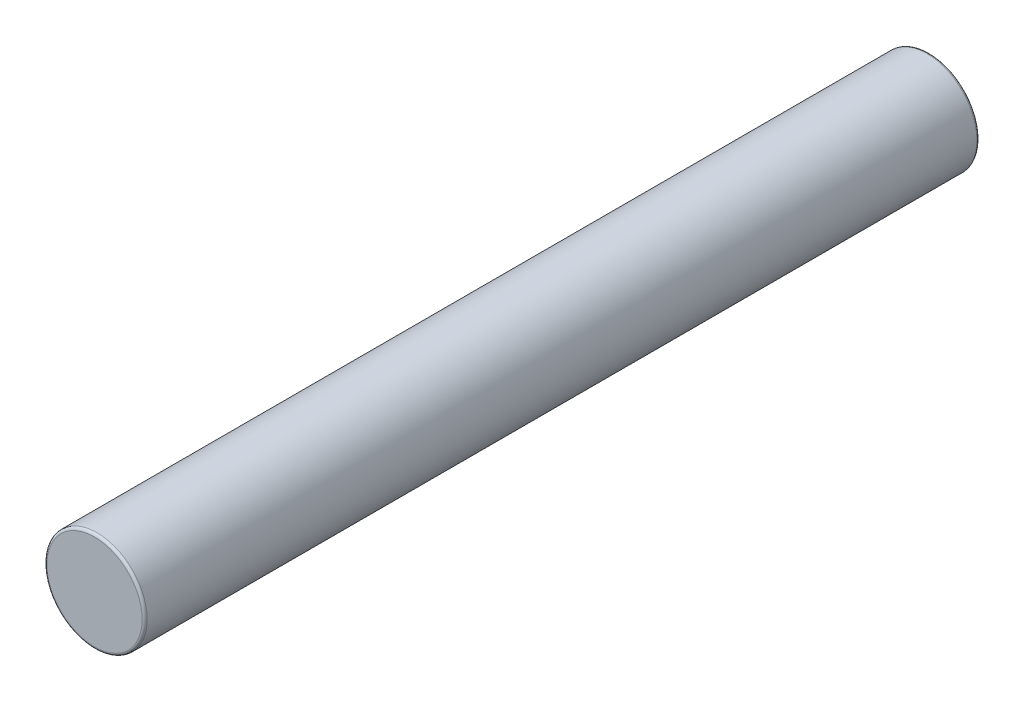
from build123d import *

# Parameters (mm, degrees)
SKETCH1_R           = 1.5
BOSS_EXTRUDE1_DEPTH = 25
FILLET1_R           = 0.075


with BuildPart() as part:
    # Sketch1 → Boss-Extrude1 (new body)
    with BuildSketch(Plane.XY):
        Circle(SKETCH1_R)
    extrude(amount=-BOSS_EXTRUDE1_DEPTH)

    # Fillet1
    fillet1_edges = [part.edges().sort_by_distance(p)[0] for p in [
        (-1.5, 0, 0),
        (-1.5, 0, -25),
    ]]
    fillet(fillet1_edges, radius=FILLET1_R)


solid = part.part
